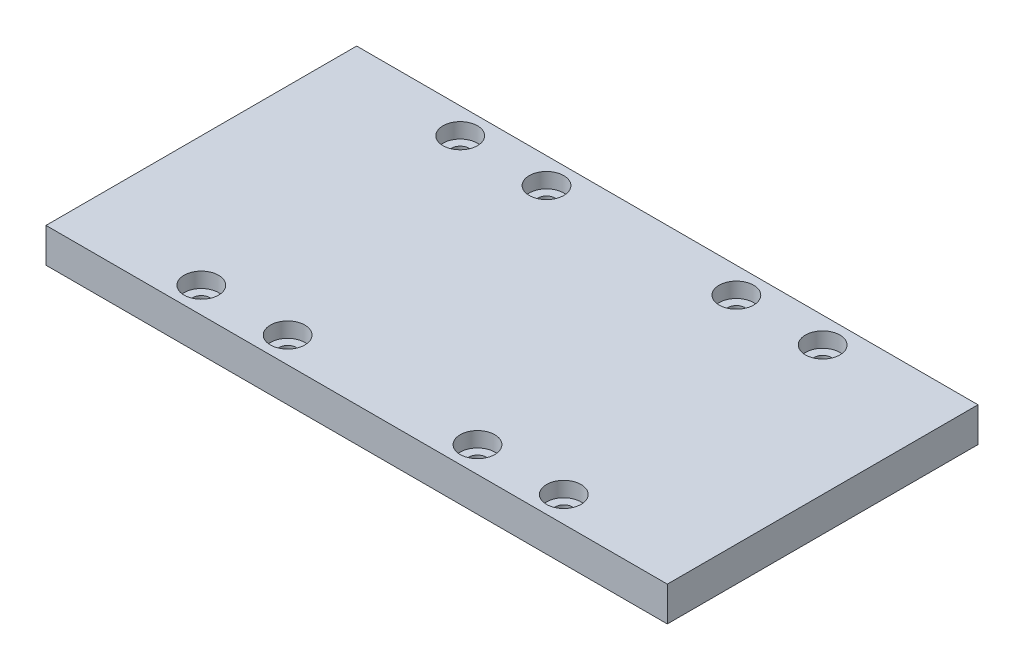
from build123d import *

# Parameters (mm, degrees)
SKETCH1_W           = 228.6
SKETCH1_H           = 114.3
BOSS_EXTRUDE1_DEPTH = 12.7
SKETCH2_R           = 3.175
CUT_EXTRUDE1_DEPTH  = 311.912
SKETCH3_R           = 6.35
CUT_EXTRUDE2_DEPTH  = 5.55625


with BuildPart() as part:
    # Sketch1 → Boss-Extrude1 (new body)
    with BuildSketch(Plane(origin=(0, 0, 0), x_dir=(1, 0, 0), z_dir=(0, 1, 0))):
        with Locations((114.3, 57.15)):
            Rectangle(SKETCH1_W, SKETCH1_H)
    extrude(amount=BOSS_EXTRUDE1_DEPTH)

    # Sketch2 → Cut-Extrude1 (cut)
    with BuildSketch(Plane.XZ):
        with Locations((47.625, -9.525)):
            Circle(SKETCH2_R)
        with Locations((79.375, -9.525)):
            Circle(SKETCH2_R)
        with Locations((149.225, -9.525)):
            Circle(SKETCH2_R)
        with Locations((180.975, -9.525)):
            Circle(SKETCH2_R)
        with Locations((47.625, -104.775)):
            Circle(SKETCH2_R)
        with Locations((79.375, -104.775)):
            Circle(SKETCH2_R)
        with Locations((149.225, -104.775)):
            Circle(SKETCH2_R)
        with Locations((180.975, -104.775)):
            Circle(SKETCH2_R)
    extrude(amount=-CUT_EXTRUDE1_DEPTH, mode=Mode.SUBTRACT)

    # Sketch3 → Cut-Extrude2 (cut)
    with BuildSketch(Plane(origin=(0, 12.7, 0), x_dir=(1, 0, 0), z_dir=(0, 1, 0))):
        with Locations((47.625, 104.775)):
            Circle(SKETCH3_R)
        with Locations((79.375, 104.775)):
            Circle(SKETCH3_R)
        with Locations((149.225, 104.775)):
            Circle(SKETCH3_R)
        with Locations((180.975, 104.775)):
            Circle(SKETCH3_R)
        with Locations((47.625, 9.525)):
            Circle(SKETCH3_R)
        with Locations((79.375, 9.525)):
            Circle(SKETCH3_R)
        with Locations((149.225, 9.525)):
            Circle(SKETCH3_R)
        with Locations((180.975, 9.525)):
            Circle(SKETCH3_R)
    extrude(amount=-CUT_EXTRUDE2_DEPTH, mode=Mode.SUBTRACT)


solid = part.part
